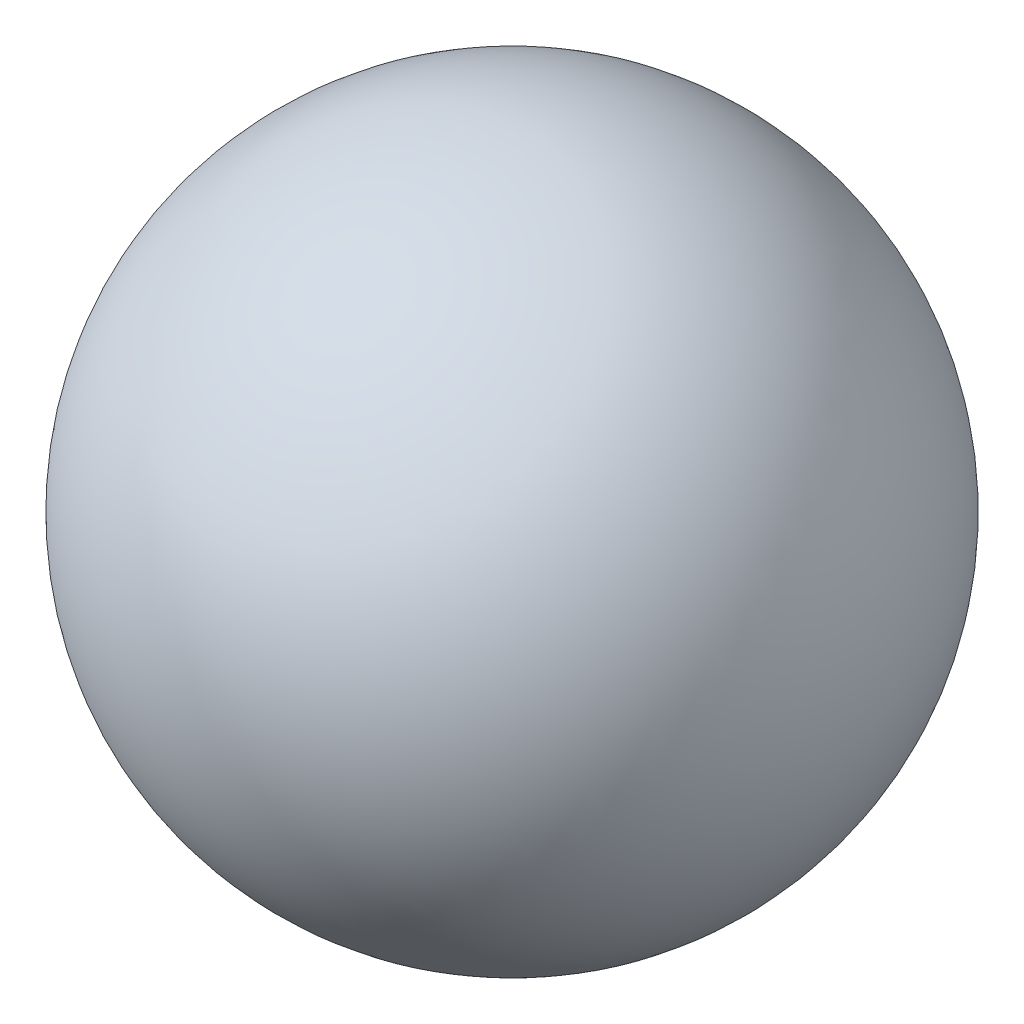
from build123d import *


with BuildPart() as part:
    # Sketch1 → Revolve1 (revolve)
    with BuildSketch(Plane.XY):
        with BuildLine():
            Line((0, 410.616562417), (0, -410.616562417))
            ThreePointArc((0, -410.616562417), (410.616562417, 0), (0, 410.616562417))
        make_face()
    revolve(axis=Axis((0, 410.616562417, 0), (0, -1, 0)))


solid = part.part
